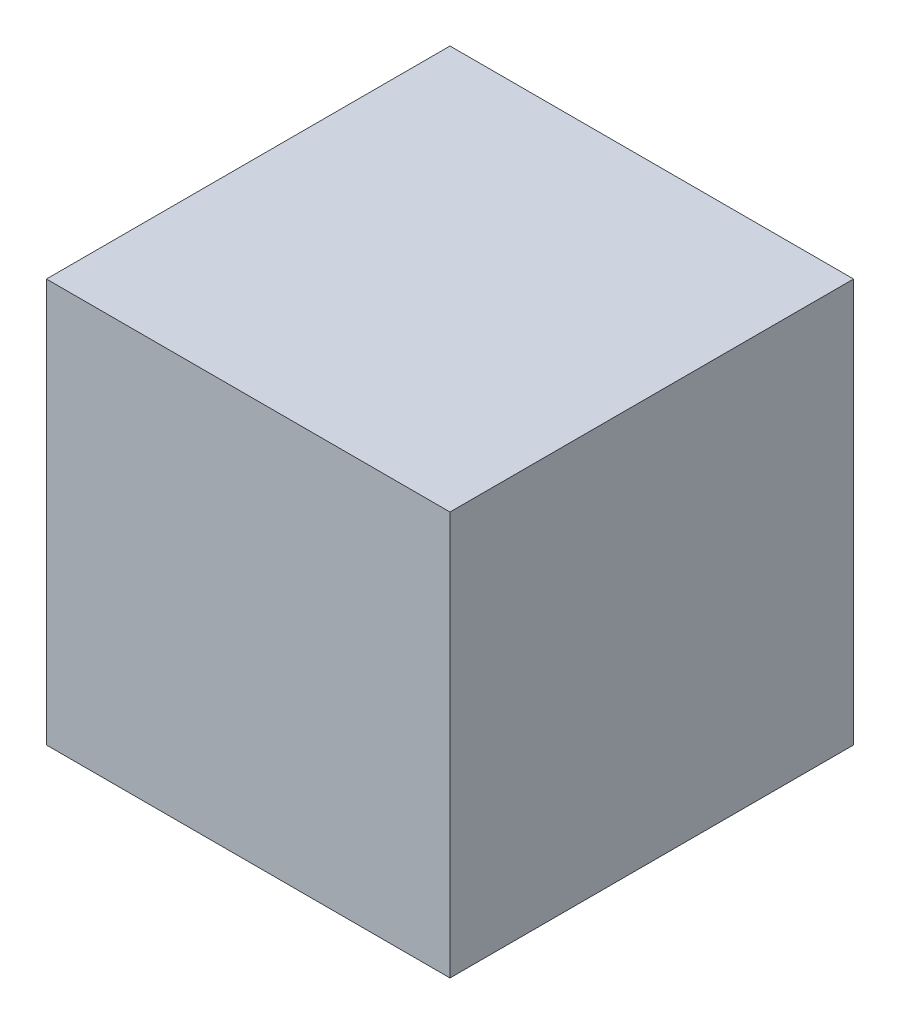
from build123d import *

# Parameters (mm, degrees)
SKETCH1_W           = 127
SKETCH1_H           = 127
BOSS_EXTRUDE1_DEPTH = 127


with BuildPart() as part:
    # Sketch1 → Boss-Extrude1 (new body)
    with BuildSketch(Plane.XY):
        with Locations((63.5, 63.5)):
            Rectangle(SKETCH1_W, SKETCH1_H)
    extrude(amount=BOSS_EXTRUDE1_DEPTH)


solid = part.part
